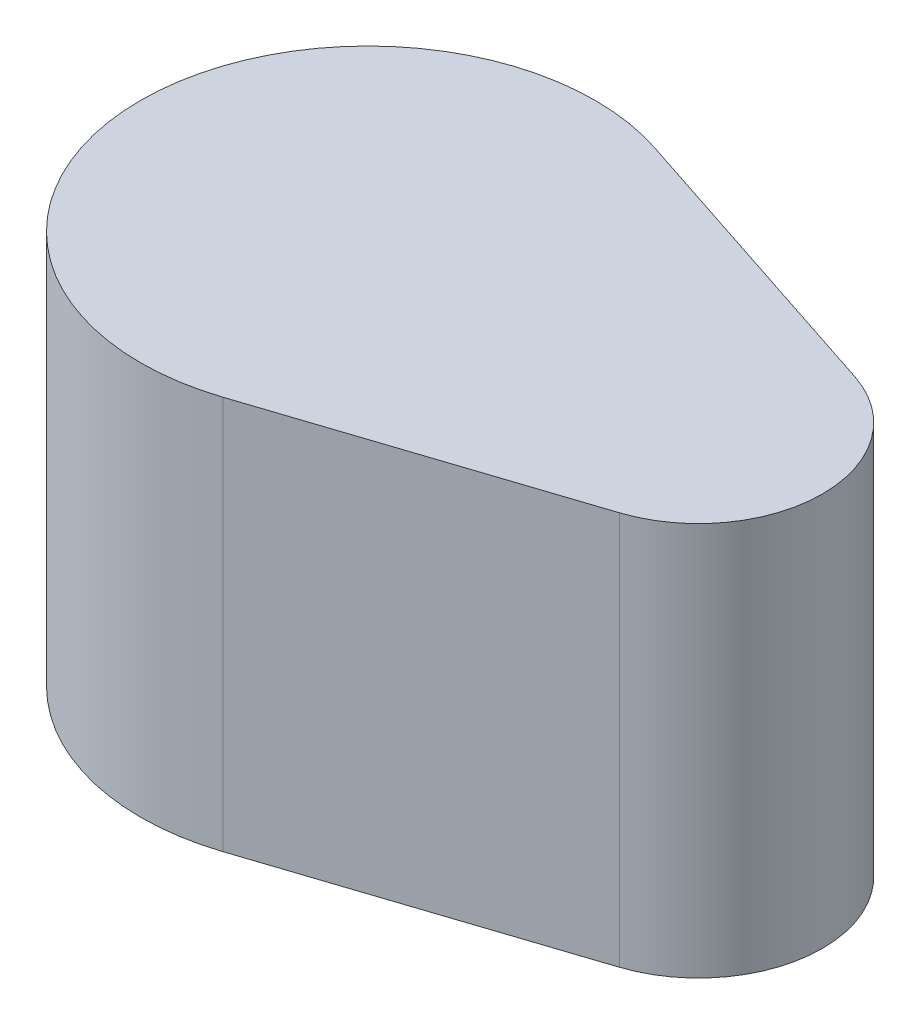
from build123d import *

# Parameters (mm, degrees)
BOSS_EXTRUDE1_DEPTH = 9.525


with BuildPart() as part:
    # Sketch1 → Boss-Extrude1 (new body)
    with BuildSketch(Plane(origin=(0, 0, 0), x_dir=(1, 0, 0), z_dir=(0, 1, 0))):
        with BuildLine():
            Line((1.71875006, 5.22454771), (8.937499975, 2.849753271))
            ThreePointArc((8.937499975, 2.849753271), (10.999999951, 0), (8.937499975, -2.849753271))
            Line((8.937499975, -2.849753271), (1.71875006, -5.22454771))
            ThreePointArc((1.71875006, -5.22454771), (-5.500000049, 0), (1.71875006, 5.22454771))
        make_face()
    extrude(amount=BOSS_EXTRUDE1_DEPTH)


solid = part.part
